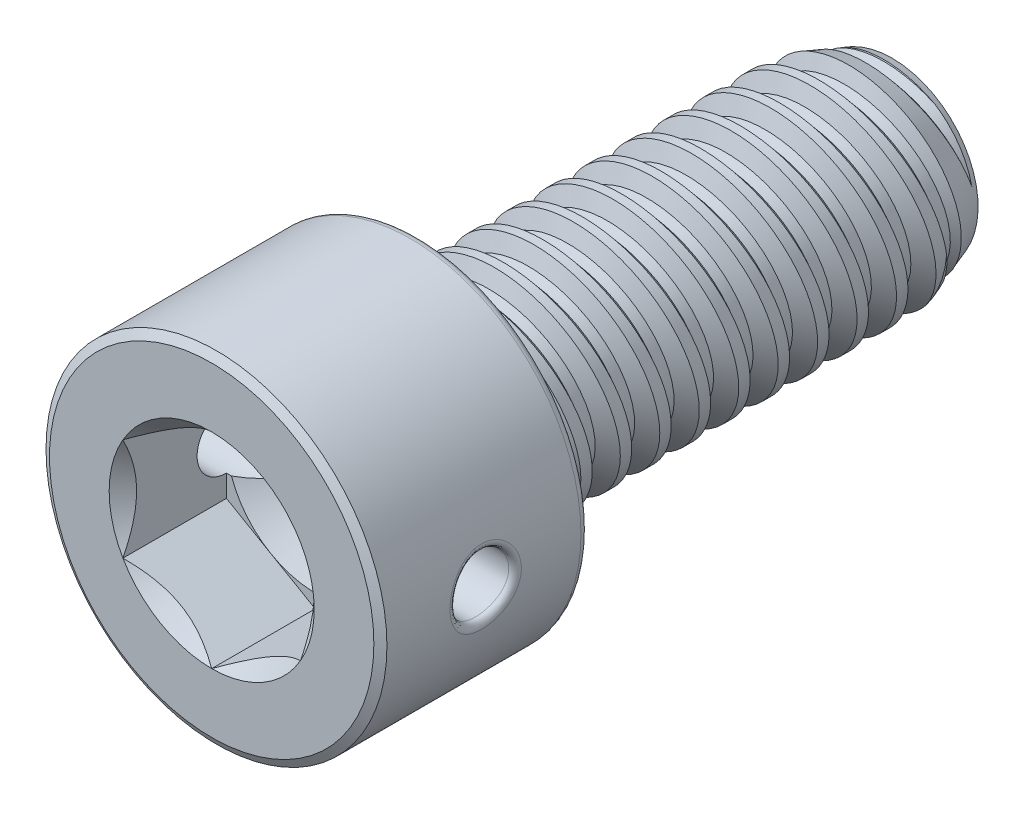
from build123d import *

# Parameters (mm, degrees)
SKETCH1_W               = 9.525
SKETCH1_H               = 2.0828
LPATTERN1_COUNT         = 12
LPATTERN1_PITCH         = 0.79375
LPATTERN2_COUNT         = 2
LPATTERN2_PITCH         = 0.79375
SKETCH4_R               = 3.429
EXTRUDE1_DEPTH          = 4.1656
SKETCH9_R               = 0.59055
CUT_EXTRUDE6_DEPTH      = 4.429
CUT_EXTRUDE6_DEPTH_BACK = 4.429
FILLET1_R               = 0.166624
CHAMFER1_SIZE           = 0.166624
CHAMFER1_SIZE2          = 0.096200411
CUT_EXTRUDE1_DEPTH      = 2.0828
SKETCH7_R               = 2.062222993
CUT_EXTRUDE4_DEPTH      = 2.0828
CUT_EXTRUDE4_DRAFT      = -45
SKETCH8_R               = 1.7859375
CUT_EXTRUDE5_DEPTH      = 0.694266667
CUT_EXTRUDE5_TAPER      = 60
FILLET2_R               = 0.127


with BuildPart() as part:
    # Sketch1 → Revolve1 (revolve)
    with BuildSketch(Plane(origin=(0, 0, 0), x_dir=(0, 0, -1), z_dir=(1, 0, 0))):
        with Locations((4.7625, 1.0414)):
            Rectangle(SKETCH1_W, SKETCH1_H)
    revolve(axis=Axis((0, 0, 0), (0, 0, 1)))

    # Sketch2 → Cut-Revolve1 (revolve, cut)
    with BuildSketch(Plane(origin=(0, 0, 0), x_dir=(0, 0, -1), z_dir=(1, 0, 0))):
        Polygon((0.097465104, 2.101371857), (0.779720832, 2.231374854), (0.61647657, 1.762908932), (0.421546362, 1.725765218), align=None)
    cut_revolve1 = revolve(axis=Axis((0, -0.162231854, 0), (0, 0.187180918, -0.982325457)), mode=Mode.SUBTRACT)

    # Sketch3 → Cut-Revolve2 (revolve, cut)
    with BuildSketch(Plane(origin=(0, 0, 0), x_dir=(0, 0, -1), z_dir=(1, 0, 0))):
        Polygon((9.525, 1.725765218), (8.544055, 2.0828), (9.525, 2.0828), align=None)
    revolve(axis=Axis((0, 0, -8.544055), (0, 0, 1)), mode=Mode.SUBTRACT)

    # LPattern1: Cut-Revolve1 ×12
    with Locations(*[(0, 0, -i * LPATTERN1_PITCH) for i in range(1, LPATTERN1_COUNT)]):
        add(cut_revolve1, mode=Mode.SUBTRACT)

    # LPattern2: Cut-Revolve1 ×2
    with Locations(*[(0, 0, i * LPATTERN2_PITCH) for i in range(1, LPATTERN2_COUNT)]):
        add(cut_revolve1, mode=Mode.SUBTRACT)

    # Sketch4 → Extrude1 (add)
    with BuildSketch(Plane.XY):
        Circle(SKETCH4_R)
    extrude(amount=EXTRUDE1_DEPTH)

    # Sketch9 → Cut-Extrude6 (cut, two sides)
    with BuildSketch(Plane(origin=(0, 0, 0), x_dir=(0, 0, -1), z_dir=(1, 0, 0))) as cut_extrude6_sk:
        with Locations((-2.0828, 0)):
            Circle(SKETCH9_R)
    extrude(amount=CUT_EXTRUDE6_DEPTH, mode=Mode.SUBTRACT)
    extrude(cut_extrude6_sk.sketch, amount=-CUT_EXTRUDE6_DEPTH_BACK, mode=Mode.SUBTRACT)

    # Fillet1
    fillet1_edges = [part.edges().sort_by_distance(p)[0] for p in [
        (-3.429, 0, 0),
    ]]
    fillet(fillet1_edges, radius=FILLET1_R)

    # Chamfer1
    chamfer1_edges = [part.edges().sort_by_distance(p)[0] for p in [
        (-3.429, 0, 4.1656),
    ]]
    chamfer1_side = [part.faces().sort_by_distance(p)[0] for p in [
        (0, 0, 4.1656),
    ]]
    chamfer(chamfer1_edges, length=CHAMFER1_SIZE, length2=CHAMFER1_SIZE2, reference=chamfer1_side[0])

    # Sketch6 → Cut-Extrude1 (cut)
    with BuildSketch(Plane.XY.offset(4.1656)):
        Polygon((0, -2.062222993), (1.7859375, -1.031111496), (1.7859375, 1.031111496), (0, 2.062222993), (-1.7859375, 1.031111496), (-1.7859375, -1.031111496), align=None)
    extrude(amount=-CUT_EXTRUDE1_DEPTH, mode=Mode.SUBTRACT)


with BuildPart() as cut_extrude4_tool:
    # Sketch7 → Cut-Extrude4 (with draft: the straight prism first)
    with BuildSketch(Plane.XY.offset(4.1656)):
        Circle(SKETCH7_R)
    extrude(amount=-CUT_EXTRUDE4_DEPTH)
    # Cut-Extrude4: the draft: its side faces are tilted about the plane it starts from
    cut_extrude4_sides = [cut_extrude4_tool.faces().sort_by_distance(p)[0] for p in [
        (-2.062222993, 0, 3.1242),
    ]]
    draft(cut_extrude4_sides, Plane.XY.offset(4.1656), CUT_EXTRUDE4_DRAFT)


with BuildPart() as part_1:
    add(part.part)

    # Cut-Extrude4: cut by cut_extrude4_tool
    add(cut_extrude4_tool.part, mode=Mode.SUBTRACT)

    # Sketch8 → Cut-Extrude5 (cut)
    with BuildSketch(Plane.XY.offset(2.0828)):
        Circle(SKETCH8_R)
    extrude(amount=-CUT_EXTRUDE5_DEPTH, taper=CUT_EXTRUDE5_TAPER, mode=Mode.SUBTRACT)

    # Fillet2
    fillet2_edges = [part_1.edges().sort_by_distance(p)[0] for p in [
        (3.377764305, 0.59055, 2.0828),
        (-3.429, 0, 2.67335),
    ]]
    fillet(fillet2_edges, radius=FILLET2_R)


solid = part_1.part
